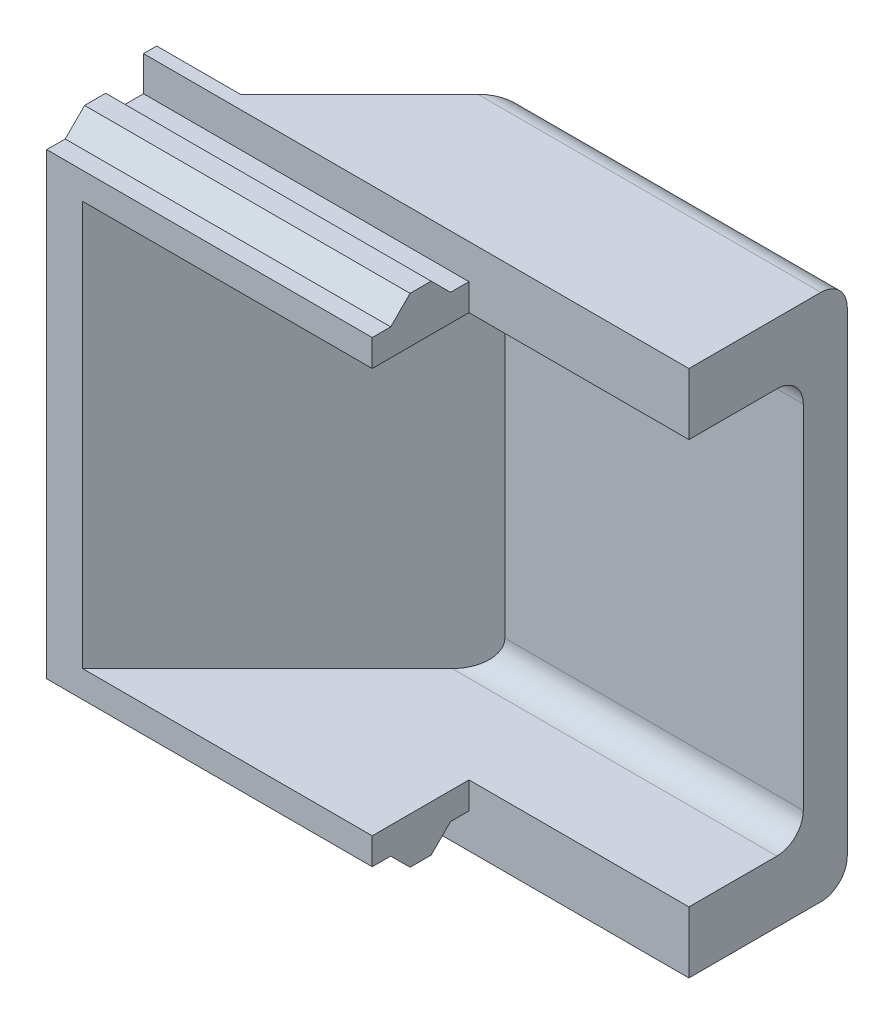
from build123d import *

# Parameters (mm, degrees)
BOSS_EXTRUDE1_DEPTH = 15.24
CUT_EXTRUDE1_DEPTH  = 16.748
CUT_EXTRUDE2_DEPTH  = 5.842
FILLET1_R           = 0.762


with BuildPart() as part:
    # Sketch1 → Boss-Extrude1 (new body)
    with BuildSketch(Plane(origin=(0, 0, 0), x_dir=(1, 0, 0), z_dir=(0, 1, 0))):
        Polygon((0, 0), (0, 3.175), (2.413, 3.175), (6.604, 7.366), (15.748, 7.366), (15.748, 2.794), (9.398, 2.794), (9.398, 0), align=None)
    extrude(amount=-BOSS_EXTRUDE1_DEPTH)

    # Sketch5 → Cut-Extrude1 (cut, through all)
    with BuildSketch(Plane.ZY):
        Polygon((0, -1.0033), (0, 0), (-2.794, 0), (-2.794, -1.0033), (-2.2606, -1.0033), (-1.7018, -0.4445), (-1.0922, -0.4445), (-0.5334, -1.0033), align=None)
    cut_extrude1 = extrude(amount=-CUT_EXTRUDE1_DEPTH, mode=Mode.SUBTRACT)

    # Mirror1: Cut-Extrude1 across plane
    add(cut_extrude1.mirror(Plane.ZX.offset(-7.62)), mode=Mode.SUBTRACT)

    # Sketch6 → Cut-Extrude2 (cut, symmetric)
    with BuildSketch(Plane(origin=(0, -7.62, 0), x_dir=(1, 0, 0), z_dir=(0, 1, 0))):
        Polygon((15.748, 6.096), (7.130051224, 6.096), (1.034051224, 0), (15.748, 0), align=None)
    extrude(amount=CUT_EXTRUDE2_DEPTH, both=True, mode=Mode.SUBTRACT)

    # Fillet1
    fillet1_edges = [part.edges().sort_by_distance(p)[0] for p in [
        (11.439025612, -13.462, -6.096),
        (11.439025612, -1.778, -6.096),
        (11.176, -15.24, -7.366),
        (11.176, 0, -7.366),
    ]]
    fillet(fillet1_edges, radius=FILLET1_R)


solid = part.part
